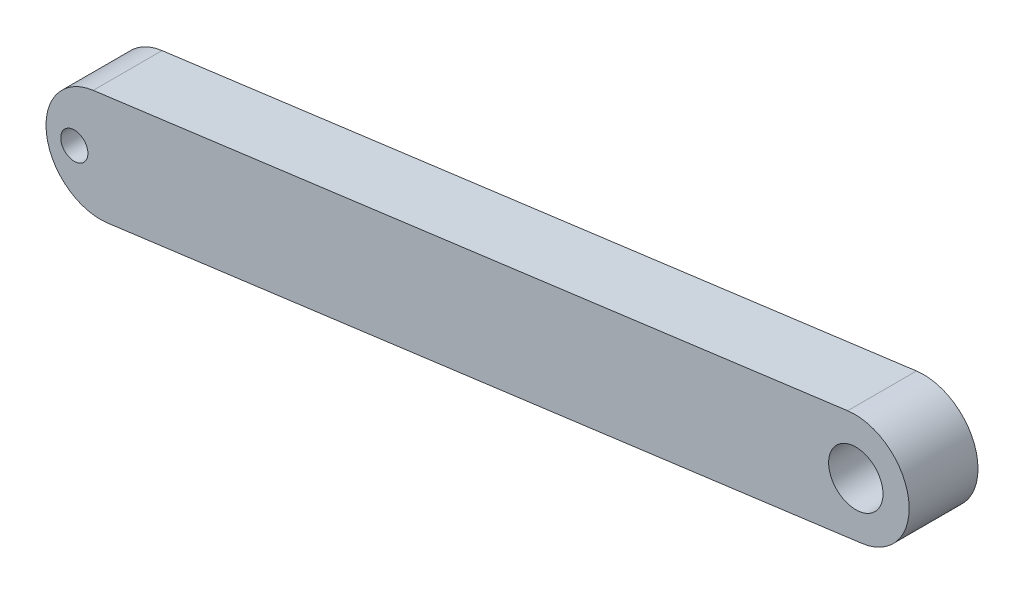
from build123d import *

# Parameters (mm, degrees)
BOSS_EXTRUDE1_DEPTH = 380
SKETCH2_R           = 150
CUT_EXTRUDE1_DEPTH  = 381
SKETCH4_R           = 75
CUT_EXTRUDE2_DEPTH  = 381


with BuildPart() as part:
    # Sketch1 → Boss-Extrude1 (new body)
    with BuildSketch(Plane.XY):
        with BuildLine():
            Line((4764.45194236, -774.716056977), (600.686121492, -1325.219634596))
            ThreePointArc((600.686121492, -1325.219634596), (342.59596126, -1661.95316306), (679.329489724, -1920.043323292))
            Line((679.329489724, -1920.043323292), (4843.095310591, -1369.539745672))
            ThreePointArc((4843.095310591, -1369.539745672), (5101.185470824, -1032.806217209), (4764.45194236, -774.716056977))
        make_face()
    extrude(amount=BOSS_EXTRUDE1_DEPTH)

    # Sketch2 → Cut-Extrude1 (cut, through all)
    with BuildSketch(Plane.XY.offset(380)):
        with Locations((4809.308774546, -1075.475725569)):
            Circle(SKETCH2_R)
    extrude(amount=-CUT_EXTRUDE1_DEPTH, mode=Mode.SUBTRACT)

    # Sketch4 → Cut-Extrude2 (cut, through all)
    with BuildSketch(Plane.XY.offset(380)):
        with Locations((496.308780647, -1641.630344573)):
            Circle(SKETCH4_R)
    extrude(amount=-CUT_EXTRUDE2_DEPTH, mode=Mode.SUBTRACT)


solid = part.part
